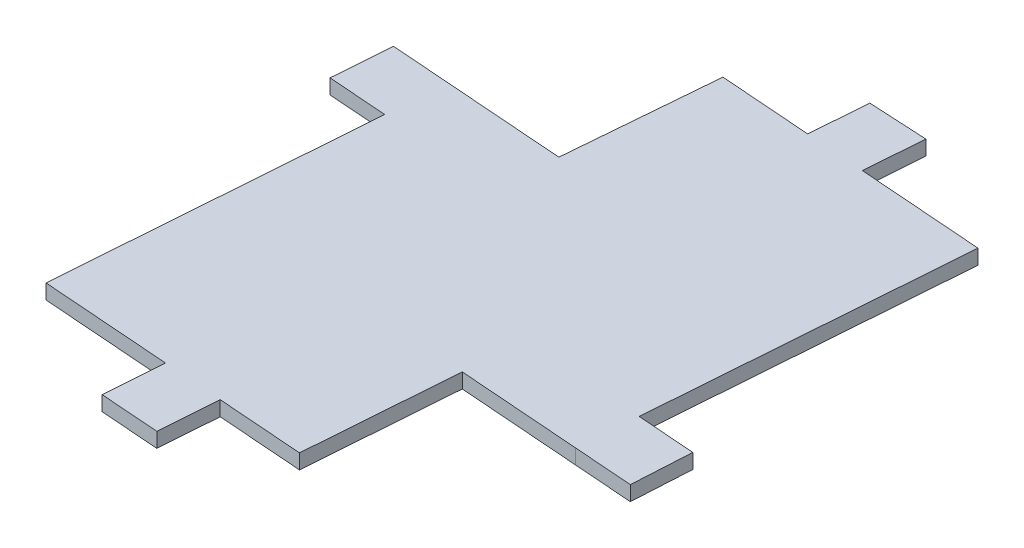
from build123d import *

# Parameters (mm, degrees)
BOSS_EXTRUDE1_DEPTH = 2


with BuildPart() as part:
    # Sketch1 → Boss-Extrude1 (new body)
    with BuildSketch(Plane(origin=(0, 0, 0), x_dir=(1, 0, 0), z_dir=(0, 1, 0))):
        Polygon((4.568528484, 43.542621579), (3.985903734, 35.734202862), (-8.386362284, 36.657358837), (-10.105460058, 16.216157585), (-26.260658602, 17.421527219), (-34.238481599, 18.01679206), (-34.833729729, 10.038968179), (-26.855906732, 9.443703338), (-30.03220272, -33.125461559), (-12.580627946, -34.427609888), (-13.175892787, -42.405432885), (-5.19806979, -43.000697726), (-4.602804949, -35.022874729), (6.965038397, -35.886008748), (8.491914931, -15.422595011), (25.050819292, -16.665973443), (33.023243687, -17.260818703), (33.478912071, -9.273111353), (25.646084989, -8.688134108), (28.842414994, 33.879535952), (11.963726758, 35.138938382), (12.558991572, 43.116761018), align=None)
    extrude(amount=BOSS_EXTRUDE1_DEPTH)


solid = part.part
